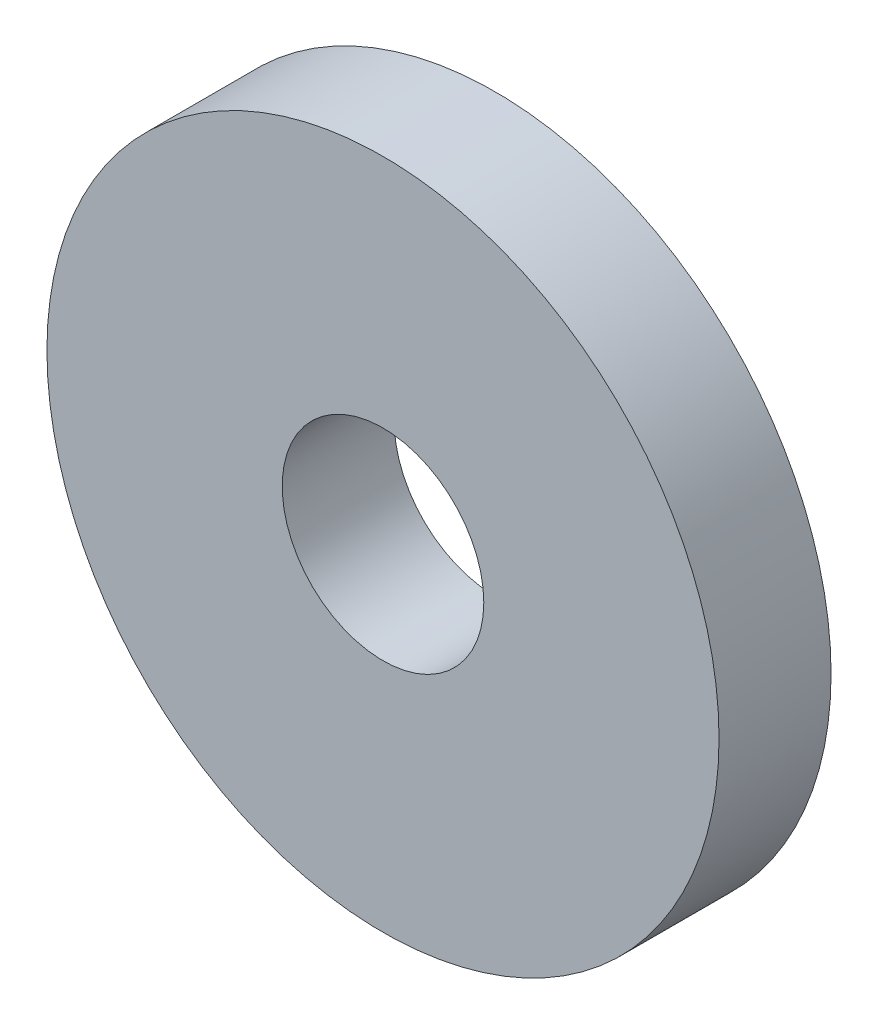
from build123d import *

# Parameters (mm, degrees)
SKETCH1_R           = 30
SKETCH1_R_2         = 9
BOSS_EXTRUDE1_DEPTH = 10


with BuildPart() as part:
    # Sketch1 → Boss-Extrude1 (new body)
    with BuildSketch(Plane.XY):
        Circle(SKETCH1_R)
        Circle(SKETCH1_R_2, mode=Mode.SUBTRACT)
    extrude(amount=BOSS_EXTRUDE1_DEPTH)


solid = part.part
